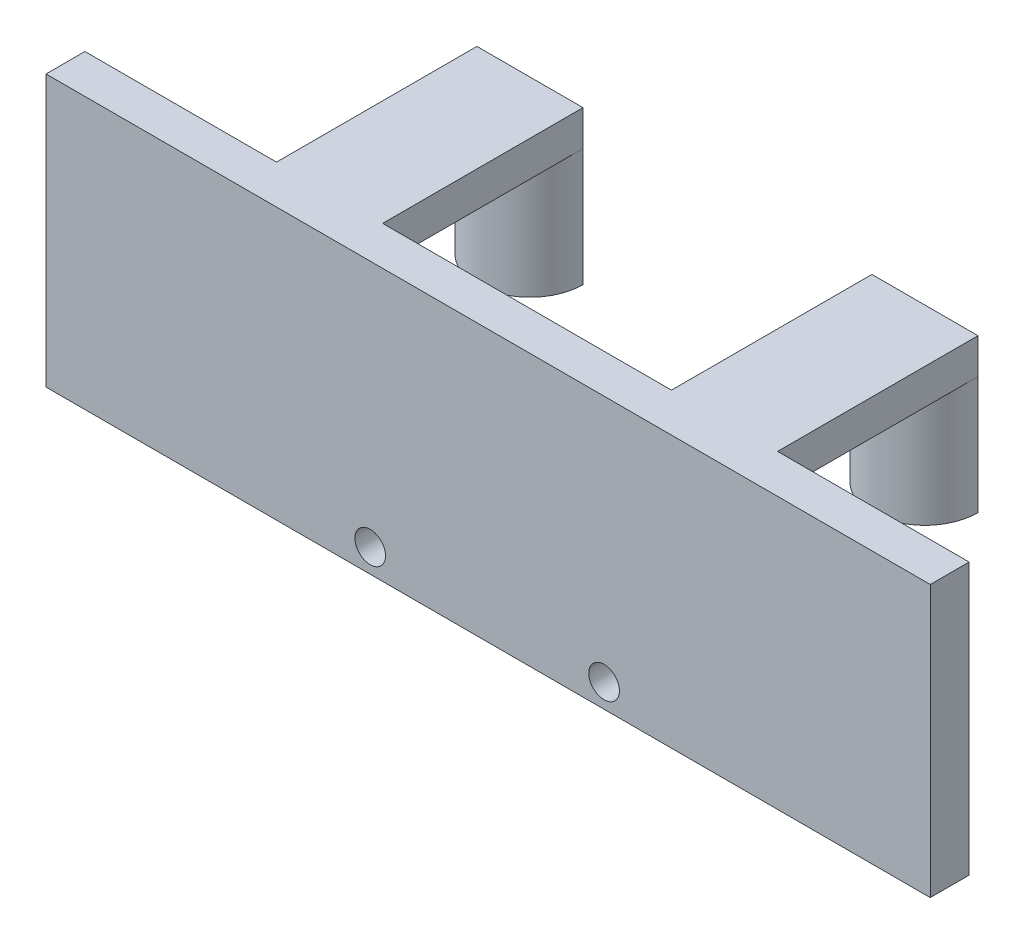
from build123d import *

# Parameters (mm, degrees)
EXTRUDE_1_DEPTH     = 23
CUT_EXTRUDE_3_DEPTH = 20
SKETCH_3_R          = 1.3
CUT_EXTRUDE_4_DEPTH = 4
SKETCH_4_W          = 42.5
SKETCH_4_H          = 6.002604642
CUT_EXTRUDE_5_DEPTH = 10


with BuildPart() as part:
    # Эскиз1 → Бобышка-Вытянуть1 (new body)
    with BuildSketch(Plane(origin=(0, 0, 0), x_dir=(1, 0, 0), z_dir=(0, 1, 0))):
        Polygon((0, 0), (-42.5, 0), (-58.75, 0), (-58.75, 3.3), (-42.5, 3.3), (-42.5, 20.3), (-33.5, 20.3), (-33.5, 3.3), (-9, 3.3), (-9, 20.3), (0, 20.3), (0, 3.3), (16.25, 3.3), (16.25, 0), align=None)
    extrude(amount=EXTRUDE_1_DEPTH)

    # Эскиз2 → Вырез-Вытянуть3 (cut)
    with BuildSketch(Plane.XZ):
        with BuildLine():
            Line((-9, -3.3), (-9, -20.3))
            ThreePointArc((-9, -20.3), (-4.5, -15.8), (0, -20.3))
            Line((0, -20.3), (0, -3.3))
            Line((0, -3.3), (-9, -3.3))
        make_face()
        with BuildLine():
            Line((-33.5, -3.3), (-42.5, -3.3))
            Line((-42.5, -3.3), (-42.5, -20.3))
            ThreePointArc((-42.5, -20.3), (-38, -15.8), (-33.5, -20.3))
            Line((-33.5, -20.3), (-33.5, -3.3))
        make_face()
    extrude(amount=-CUT_EXTRUDE_3_DEPTH, mode=Mode.SUBTRACT)

    # Эскиз3 → Вырез-Вытянуть4 (cut)
    with BuildSketch(Plane.XY):
        with Locations((-31.25, 2)):
            Circle(SKETCH_3_R)
        with Locations((-11.41399061, 2)):
            Circle(SKETCH_3_R)
    extrude(amount=-CUT_EXTRUDE_4_DEPTH, mode=Mode.SUBTRACT)

    # Эскиз4 → Вырез-Вытянуть5 (cut)
    with BuildSketch(Plane.XZ):
        with Locations((-21.25, -17.298697679)):
            Rectangle(SKETCH_4_W, SKETCH_4_H)
    extrude(amount=-CUT_EXTRUDE_5_DEPTH, mode=Mode.SUBTRACT)


solid = part.part
